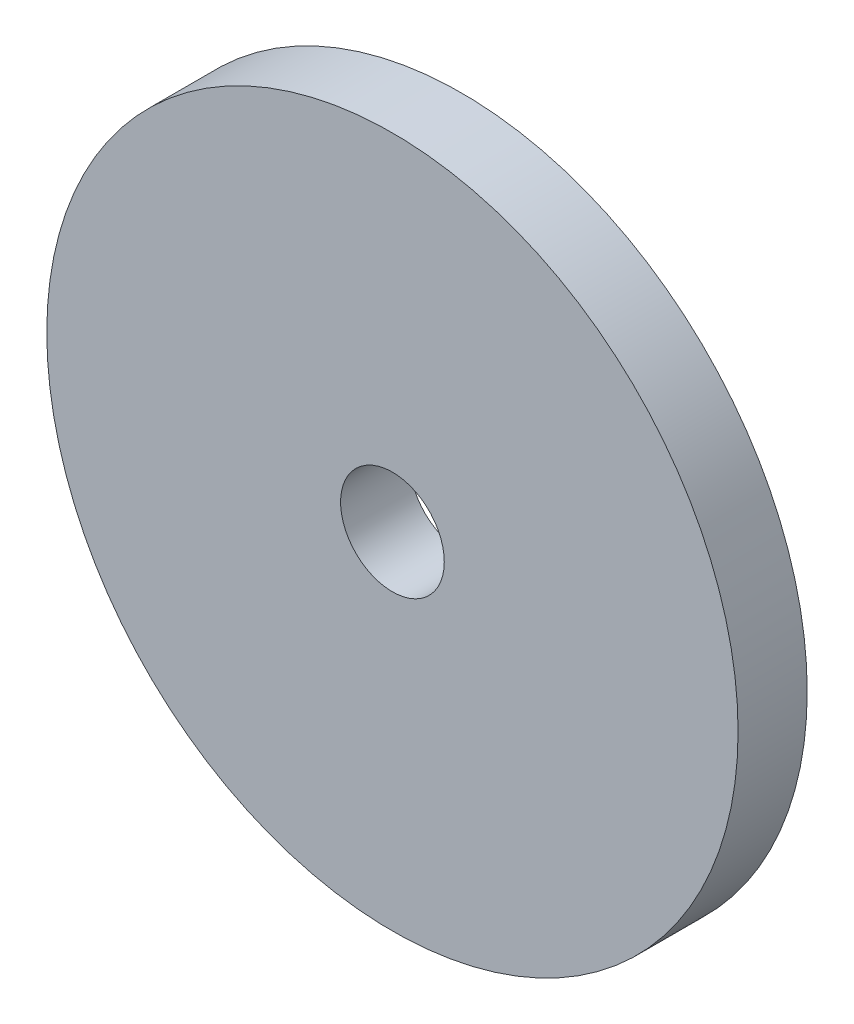
from build123d import *

# Parameters (mm, degrees)
SKETCH1_R           = 10
SKETCH1_R_2         = 1.5
BOSS_EXTRUDE1_DEPTH = 2


with BuildPart() as part:
    # Sketch1 → Boss-Extrude1 (new body)
    with BuildSketch(Plane.XY):
        Circle(SKETCH1_R)
        Circle(SKETCH1_R_2, mode=Mode.SUBTRACT)
    extrude(amount=BOSS_EXTRUDE1_DEPTH)


solid = part.part
